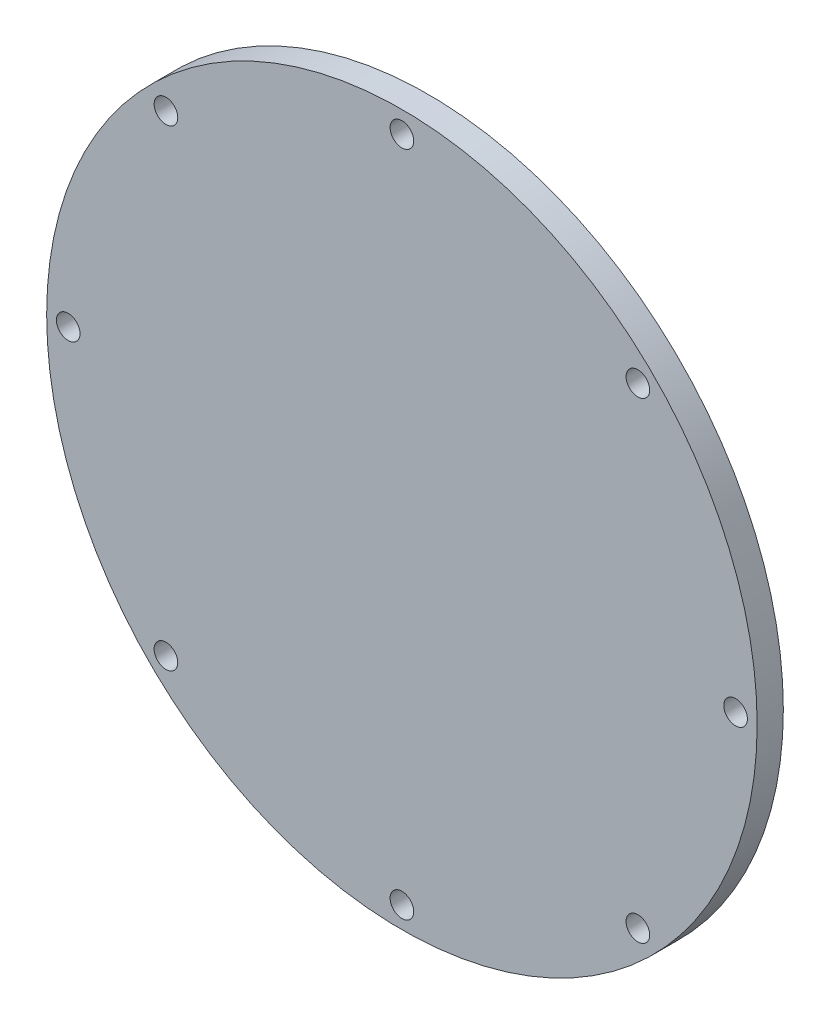
from build123d import *

# Parameters (mm, degrees)
SKETCH1_R                      = 76
BOSS_EXTRUDE1_DEPTH            = 5.6
F_8_0_199_DIAMETER_HOLE1_D     = 5.0546
F_8_0_199_DIAMETER_HOLE1_DEPTH = 8.481444958
F_8_0_199_DIAMETER_HOLE1_TIP   = 1.518555042


with BuildPart() as part:
    # Sketch1 → Boss-Extrude1 (new body)
    with BuildSketch(Plane.XY):
        Circle(SKETCH1_R)
    extrude(amount=BOSS_EXTRUDE1_DEPTH)

    # #8 (0.199) Diameter Hole1
    with Locations(Plane(origin=(0, 0, 0), x_dir=(-1, 0, 0), z_dir=(0, 0, -1))):
        with Locations((-50.478019657, 50.478019657), (0, 71.3867), (50.478019657, 50.478019657), (71.3867, 0), (50.478019657, -50.478019657), (0, -71.3867), (-50.478019657, -50.478019657), (-71.3867, 0)):
            Hole(F_8_0_199_DIAMETER_HOLE1_D / 2, depth=F_8_0_199_DIAMETER_HOLE1_DEPTH)
            with Locations((0, 0, -(F_8_0_199_DIAMETER_HOLE1_DEPTH + F_8_0_199_DIAMETER_HOLE1_TIP / 2))):  # 118° drill point
                Cone(0, F_8_0_199_DIAMETER_HOLE1_D / 2, F_8_0_199_DIAMETER_HOLE1_TIP, mode=Mode.SUBTRACT)


solid = part.part
